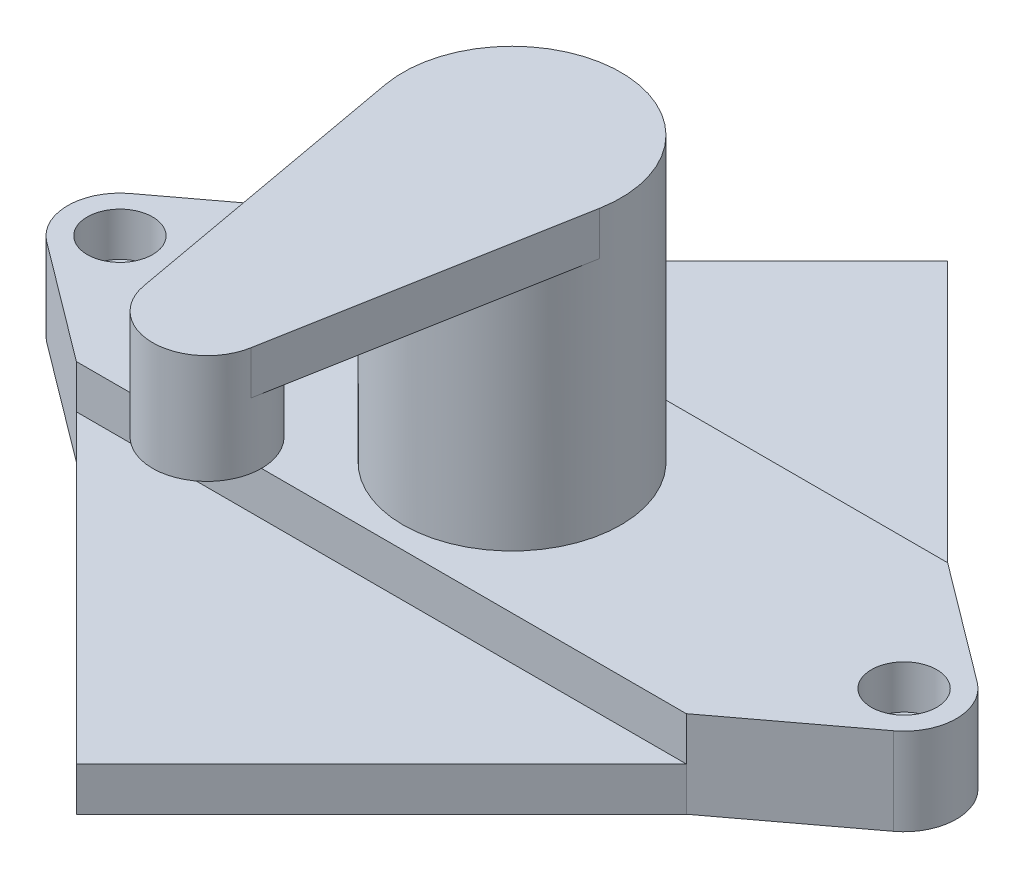
from build123d import *

# Parameters (mm, degrees)
SALIENTE_EXTRUIR1_DEPTH                     = 10
SALIENTE_EXTRUIR1_2_DEPTH                   = 10
CROQUIS2_3_R                                = 25
SALIENTE_EXTRUIR2_DEPTH                     = 20
CROQUIS2_4_R                                = 25
SALIENTE_EXTRUIR3_DEPTH                     = 85
SALIENTE_EXTRUIR4_START                     = -10
SALIENTE_EXTRUIR4_DEPTH                     = 10
SALIENTE_EXTRUIR5_START                     = -25
SALIENTE_EXTRUIR5_DEPTH                     = 25
AVELLANADO_PARA_TORNILLO_CON_CABEZA_2_COUNT = 2
AVELLANADO_PARA_TORNILLO_CON_CABEZA_2_PITCH = 180


with BuildPart() as part:
    # Croquis2 → Saliente-Extruir1 (new body)
    with BuildSketch(Plane(origin=(0, 0, 0), x_dir=(1, 0, 0), z_dir=(0, 1, 0))):
        Polygon((0, 100), (-70, 30), (70, 30), align=None)
    extrude(amount=SALIENTE_EXTRUIR1_DEPTH)



with BuildPart() as body_2:
    # Croquis2 → Saliente-Extruir1 2 (new body)
    with BuildSketch(Plane(origin=(0, 0, 0), x_dir=(1, 0, 0), z_dir=(0, 1, 0))):
        Polygon((70, -30), (-70, -30), (0, -100), align=None)
    extrude(amount=SALIENTE_EXTRUIR1_2_DEPTH)


with BuildPart() as part_1:
    add(part.part)

    add(body_2.part)  # Saliente-Extruir2 merges body 2
    # Croquis2_3 → Saliente-Extruir2 (add)
    with BuildSketch(Plane(origin=(0, 0, 0), x_dir=(1, 0, 0), z_dir=(0, 1, 0))):
        with BuildLine():
            Line((-70, 30), (-97.2, 9.6))
            ThreePointArc((-97.2, 9.6), (-102, 0), (-97.2, -9.6))
            Line((-97.2, -9.6), (-70, -30))
            Line((-70, -30), (70, -30))
            Line((70, -30), (97.2, -9.6))
            ThreePointArc((97.2, -9.6), (102, 0), (97.2, 9.6))
            Line((97.2, 9.6), (70, 30))
            Line((70, 30), (-70, 30))
        make_face()
        Circle(CROQUIS2_3_R, mode=Mode.SUBTRACT)
    extrude(amount=SALIENTE_EXTRUIR2_DEPTH)

    # Croquis2_4 → Saliente-Extruir3 (add)
    with BuildSketch(Plane(origin=(0, 0, 0), x_dir=(1, 0, 0), z_dir=(0, 1, 0))):
        Circle(CROQUIS2_4_R)
    extrude(amount=SALIENTE_EXTRUIR3_DEPTH)

    # Croquis3 → Saliente-Extruir4 (add)
    with BuildSketch(Plane(origin=(0, 85, 0), x_dir=(1, 0, 0), z_dir=(0, 1, 0)).offset(SALIENTE_EXTRUIR4_START)):
        with BuildLine():
            ThreePointArc((24.598173775, -4.464285714), (0, -25), (-24.598173775, -4.464285714))
            Line((-24.598173775, -4.464285714), (-12.299086887, -72.232142857))
            ThreePointArc((-12.299086887, -72.232142857), (-1.120583309, -57.550329601), (12.5, -70))
            ThreePointArc((12.5, -70), (12.449670399, -71.120583309), (12.299086887, -72.232142857))
            Line((12.299086887, -72.232142857), (24.598173775, -4.464285714))
        make_face()
    extrude(amount=SALIENTE_EXTRUIR4_DEPTH)

    # Croquis3_3 → Saliente-Extruir5 (add)
    with BuildSketch(Plane(origin=(0, 85, 0), x_dir=(1, 0, 0), z_dir=(0, 1, 0)).offset(SALIENTE_EXTRUIR5_START)):
        with BuildLine():
            ThreePointArc((12.299086887, -72.232142857), (12.449670399, -71.120583309), (12.5, -70))
            ThreePointArc((12.5, -70), (-1.120583309, -57.550329601), (-12.299086887, -72.232142857))
            ThreePointArc((-12.299086887, -72.232142857), (0, -82.5), (12.299086887, -72.232142857))
        make_face()
    extrude(amount=SALIENTE_EXTRUIR5_DEPTH)

    # Croquis6 → Avellanado para tornillo con cabeza oval (revolve, cut)
    with BuildSketch(Plane(origin=(90, 20, 0), x_dir=(0, 0, 1), z_dir=(1, 0, 0))):
        Polygon((0, 0), (0, 20), (3.499999985, 20), (3.499999985, 14.60147363), (7.499999986, 10), (7.499999986, 0), align=None)
    avellanado_para_tornillo_con_cabeza_oval = revolve(axis=Axis((90, 26.35, 0), (0, -1, 0)), mode=Mode.SUBTRACT)

    # Avellanado para tornillo con cabeza  2: Avellanado para tornillo con cabeza oval ×2
    with Locations(*[(-i * AVELLANADO_PARA_TORNILLO_CON_CABEZA_2_PITCH, 0, 0) for i in range(1, AVELLANADO_PARA_TORNILLO_CON_CABEZA_2_COUNT)]):
        add(avellanado_para_tornillo_con_cabeza_oval, mode=Mode.SUBTRACT)


solid = part_1.part
